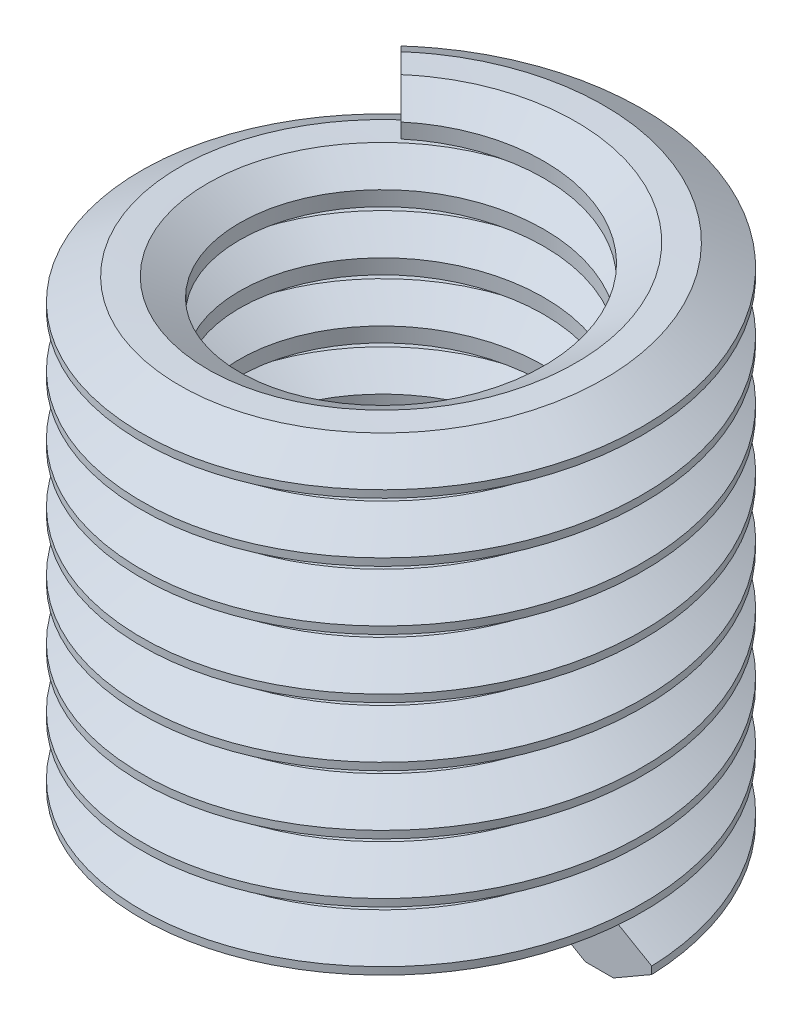
from build123d import *

# Parameters (mm, degrees)
SWEEP1_PITCH       = 0.8
SWEEP1_HEIGHT      = 6.7
SWEEP1_RADIUS      = 2.5
SWEEP1_START_ANGLE = 90


with BuildPart() as part:
    # Sweep1: sweep along a helix
    with BuildLine() as sweep1_path:
        add(Helix(SWEEP1_PITCH, SWEEP1_HEIGHT, SWEEP1_RADIUS, center=(0, 0, 0), direction=(0, 1, 0), mode=Mode.PRIVATE).rotate(Axis((0, 0, 0), (0, 1, 0)), SWEEP1_START_ANGLE))
    # Sketch1 → Sweep1 (sweep)
    with BuildSketch(Plane(origin=(0, 0, 0), x_dir=(-1, 0, 0), z_dir=(0, 0, 1))):
        Polygon((-3.4, -0.05), (-2.880384758, -0.35), (-2.5, -0.35), (-2.066987298, -0.1), (-2.066987298, 0.1), (-2.5, 0.35), (-2.880384758, 0.35), (-3.4, 0.05), align=None)
    sweep(path=sweep1_path.line, is_frenet=True)


solid = part.part
